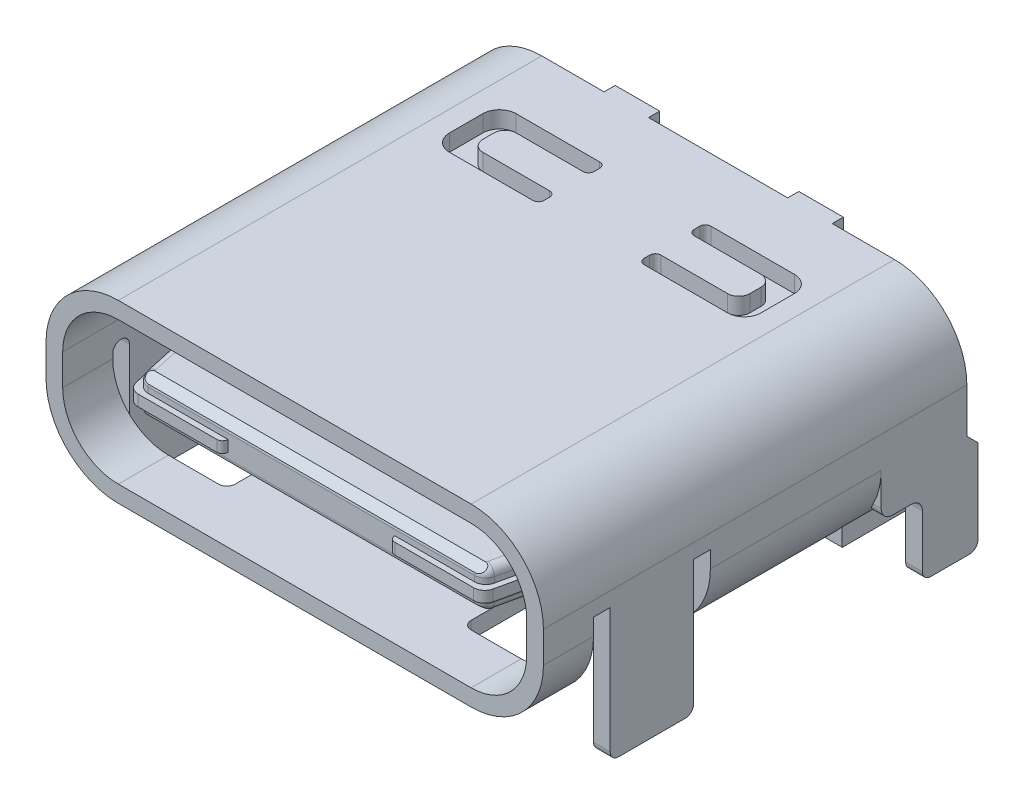
from build123d import *

# Parameters (mm, degrees)
BOSS_EXTRUDE1_DEPTH    = 7.61
SKETCH2_OUTSIDE_W      = 13.372
SKETCH2_OUTSIDE_H      = 7.592
CUT_EXTRUDE1_DEPTH     = 4.7
CUT_EXTRUDE2_DEPTH     = 0.3
BOSS_EXTRUDE2_DEPTH    = 0.2
BOSS_EXTRUDE3_DEPTH    = 0.3
CUT_EXTRUDE3_DEPTH     = 1.6
SKETCH7_W              = 8.34
SKETCH7_H              = 1.94
CUT_EXTRUDE4_DEPTH     = 0.15
BOSS_EXTRUDE4_DEPTH    = 1.94
BOSS_EXTRUDE5_DEPTH    = 0.2
BOSS_EXTRUDE5_2_DEPTH  = 0.2
BOSS_EXTRUDE5_3_DEPTH  = 0.2
BOSS_EXTRUDE5_4_DEPTH  = 0.2
BOSS_EXTRUDE5_5_DEPTH  = 0.2
BOSS_EXTRUDE5_6_DEPTH  = 0.2
BOSS_EXTRUDE5_7_DEPTH  = 0.2
BOSS_EXTRUDE5_8_DEPTH  = 0.2
BOSS_EXTRUDE5_9_DEPTH  = 0.2
BOSS_EXTRUDE5_10_DEPTH = 0.2
BOSS_EXTRUDE5_11_DEPTH = 0.2
BOSS_EXTRUDE5_12_DEPTH = 0.2
BOSS_EXTRUDE5_13_DEPTH = 0.2
BOSS_EXTRUDE5_14_DEPTH = 0.2
BOSS_EXTRUDE5_15_DEPTH = 0.2
BOSS_EXTRUDE5_16_DEPTH = 0.2
BOSS_EXTRUDE5_17_DEPTH = 0.2
BOSS_EXTRUDE5_18_DEPTH = 0.2
BOSS_EXTRUDE5_19_DEPTH = 0.2
BOSS_EXTRUDE5_20_DEPTH = 0.2
BOSS_EXTRUDE5_21_DEPTH = 0.2
BOSS_EXTRUDE5_22_DEPTH = 0.2
BOSS_EXTRUDE5_23_DEPTH = 0.2
BOSS_EXTRUDE5_24_DEPTH = 0.2
BOSS_EXTRUDE5_25_DEPTH = 0.2
BOSS_EXTRUDE5_26_DEPTH = 0.2
CUT_EXTRUDE5_START     = -6.55
CUT_EXTRUDE5_DEPTH     = 6.9
CUT_EXTRUDE6_DEPTH     = 6.2
BOSS_EXTRUDE6_DEPTH    = 1.62
BOSS_EXTRUDE7_DEPTH    = 0.35
BOSS_EXTRUDE8_DEPTH    = 0.1
BOSS_EXTRUDE8_2_DEPTH  = 0.1
FILLET2_R              = 0.15
CUT_EXTRUDE10_DEPTH    = 9.9400001


with BuildPart() as part:
    # Sketch1 → Boss-Extrude1 (new body)
    with BuildSketch(Plane.XY):
        with BuildLine():
            Line((-4.47, 0.28), (-4.47, -0.28))
            ThreePointArc((-4.47, -0.28), (-4.089238816, -1.199238816), (-3.17, -1.58))
            Line((-3.17, -1.58), (3.17, -1.58))
            ThreePointArc((3.17, -1.58), (4.089238816, -1.199238816), (4.47, -0.28))
            Line((4.47, -0.28), (4.47, 0.28))
            ThreePointArc((4.47, 0.28), (4.089238816, 1.199238816), (3.17, 1.58))
            Line((3.17, 1.58), (-3.17, 1.58))
            ThreePointArc((-3.17, 1.58), (-4.089238816, 1.199238816), (-4.47, 0.28))
        make_face()
    extrude(amount=BOSS_EXTRUDE1_DEPTH)

    # Sketch2 outside → Cut-Extrude1 (cut)
    with BuildSketch(Plane.XY.offset(7.61)):
        Rectangle(SKETCH2_OUTSIDE_W, SKETCH2_OUTSIDE_H)
        with BuildLine():
            Line((-4.47, 0.28), (-4.47, -0.28))
            ThreePointArc((-4.47, -0.28), (-4.089238816, -1.199238816), (-3.17, -1.58))
            Line((-3.17, -1.58), (3.17, -1.58))
            ThreePointArc((3.17, -1.58), (4.089238816, -1.199238816), (4.47, -0.28))
            Line((4.47, -0.28), (4.47, 0.28))
            ThreePointArc((4.47, 0.28), (4.089238816, 1.199238816), (3.17, 1.58))
            Line((3.17, 1.58), (-3.17, 1.58))
            ThreePointArc((-3.17, 1.58), (-4.089238816, 1.199238816), (-4.47, 0.28))
        make_face(mode=Mode.SUBTRACT)
        with BuildLine():
            Line((3.17, 1.28), (-3.17, 1.28))
            ThreePointArc((-3.17, 1.28), (-3.877106781, 0.987106781), (-4.17, 0.28))
            Line((-4.17, 0.28), (-4.17, -0.28))
            ThreePointArc((-4.17, -0.28), (-3.877106781, -0.987106781), (-3.17, -1.28))
            Line((-3.17, -1.28), (3.17, -1.28))
            ThreePointArc((3.17, -1.28), (3.877106781, -0.987106781), (4.17, -0.28))
            Line((4.17, -0.28), (4.17, 0.28))
            ThreePointArc((4.17, 0.28), (3.877106781, 0.987106781), (3.17, 1.28))
        make_face()
    extrude(amount=-CUT_EXTRUDE1_DEPTH, mode=Mode.SUBTRACT)

    # Sketch3 → Cut-Extrude2 (cut)
    with BuildSketch(Plane(origin=(0, 1.58, 0), x_dir=(1, 0, 0), z_dir=(0, 1, 0))):
        with BuildLine():
            Line((-0.9, -1.33), (-0.9, -1.23))
            ThreePointArc((-0.9, -1.23), (-0.929289322, -1.159289322), (-1, -1.13))
            Line((-1, -1.13), (-2.5, -1.13))
            ThreePointArc((-2.5, -1.13), (-2.712132034, -1.217867966), (-2.8, -1.43))
            Line((-2.8, -1.43), (-2.8, -2.03))
            ThreePointArc((-2.8, -2.03), (-2.712132034, -2.242132034), (-2.5, -2.33))
            Line((-2.5, -2.33), (-1, -2.33))
            ThreePointArc((-1, -2.33), (-0.929289322, -2.300710678), (-0.9, -2.23))
            Line((-0.9, -2.23), (-0.9, -2.13))
            ThreePointArc((-0.9, -2.13), (-0.929289322, -2.059289322), (-1, -2.03))
            Line((-1, -2.03), (-2.2, -2.03))
            ThreePointArc((-2.2, -2.03), (-2.341421356, -1.971421356), (-2.4, -1.83))
            Line((-2.4, -1.83), (-2.4, -1.63))
            ThreePointArc((-2.4, -1.63), (-2.341421356, -1.488578644), (-2.2, -1.43))
            Line((-2.2, -1.43), (-1, -1.43))
            ThreePointArc((-1, -1.43), (-0.929289322, -1.400710678), (-0.9, -1.33))
        make_face()
        with BuildLine():
            Line((2.5, -1.13), (1, -1.13))
            ThreePointArc((1, -1.13), (0.929289322, -1.159289322), (0.9, -1.23))
            Line((0.9, -1.23), (0.9, -1.33))
            ThreePointArc((0.9, -1.33), (0.929289322, -1.400710678), (1, -1.43))
            Line((1, -1.43), (2.2, -1.43))
            ThreePointArc((2.2, -1.43), (2.341421356, -1.488578644), (2.4, -1.63))
            Line((2.4, -1.63), (2.4, -1.83))
            ThreePointArc((2.4, -1.83), (2.341421356, -1.971421356), (2.2, -2.03))
            Line((2.2, -2.03), (1, -2.03))
            ThreePointArc((1, -2.03), (0.929289322, -2.059289322), (0.9, -2.13))
            Line((0.9, -2.13), (0.9, -2.23))
            ThreePointArc((0.9, -2.23), (0.929289322, -2.300710678), (1, -2.33))
            Line((1, -2.33), (2.5, -2.33))
            ThreePointArc((2.5, -2.33), (2.712132034, -2.242132034), (2.8, -2.03))
            Line((2.8, -2.03), (2.8, -1.43))
            ThreePointArc((2.8, -1.43), (2.712132034, -1.217867966), (2.5, -1.13))
        make_face()
    extrude(amount=-CUT_EXTRUDE2_DEPTH, mode=Mode.SUBTRACT)

    # Sketch4 → Boss-Extrude2 (add)
    with BuildSketch(Plane(origin=(0, 0, 0), x_dir=(-1, 0, 0), z_dir=(0, 0, -1))):
        with BuildLine():
            Line((-3.97, 0.48), (-3.97, -0.42))
            ThreePointArc((-3.97, -0.42), (-3.882132034, -0.632132034), (-3.67, -0.72))
            Line((-3.67, -0.72), (3.67, -0.72))
            ThreePointArc((3.67, -0.72), (3.882132034, -0.632132034), (3.97, -0.42))
            Line((3.97, -0.42), (3.97, 0.48))
            ThreePointArc((3.97, 0.48), (3.823553391, 0.833553391), (3.47, 0.98))
            Line((3.47, 0.98), (2.05, 0.98))
            Line((2.05, 0.98), (2.05, 1.58))
            Line((2.05, 1.58), (1.25, 1.58))
            Line((1.25, 1.58), (1.25, 0.98))
            Line((1.25, 0.98), (-1.25, 0.98))
            Line((-1.25, 0.98), (-1.25, 1.58))
            Line((-1.25, 1.58), (-2.05, 1.58))
            Line((-2.05, 1.58), (-2.05, 0.98))
            Line((-2.05, 0.98), (-3.47, 0.98))
            ThreePointArc((-3.47, 0.98), (-3.823553391, 0.833553391), (-3.97, 0.48))
        make_face()
    extrude(amount=BOSS_EXTRUDE2_DEPTH)

    # Sketch5 → Boss-Extrude3 (add)
    with BuildSketch(Plane(origin=(4.47, 0, 0), x_dir=(0, 0, -1), z_dir=(1, 0, 0))):
        with BuildLine():
            Line((-4.91, -0.28), (-6.41, -0.28))
            Line((-6.41, -0.28), (-6.41, -2.23))
            ThreePointArc((-6.41, -2.23), (-6.366066017, -2.336066017), (-6.26, -2.38))
            Line((-6.26, -2.38), (-5.06, -2.38))
            ThreePointArc((-5.06, -2.38), (-4.953933983, -2.336066017), (-4.91, -2.23))
            Line((-4.91, -2.23), (-4.91, -0.28))
        make_face()
        with BuildLine():
            ThreePointArc((-6.71, -0.2), (-6.56, -0.05), (-6.41, -0.2))
            Line((-6.41, -0.2), (-6.41, -0.28))
            Line((-6.41, -0.28), (-4.91, -0.28))
            Line((-4.91, -0.28), (-4.91, -0.2))
            ThreePointArc((-4.91, -0.2), (-4.76, -0.05), (-4.61, -0.2))
            Line((-4.61, -0.2), (-4.61, -0.28))
            Line((-4.61, -0.28), (-1.54, -0.28))
            Line((-1.54, -0.28), (0, -0.28))
            Line((0, -0.28), (0, 0.209679923))
            Line((0, 0.209679923), (-7.61, 0.209679923))
            Line((-7.61, 0.209679923), (-7.61, -0.28))
            Line((-7.61, -0.28), (-6.71, -0.28))
            Line((-6.71, -0.28), (-6.71, -0.2))
        make_face()
        with BuildLine():
            Line((0, -0.28), (-1.54, -0.28))
            Line((-1.54, -0.28), (-1.54, -0.88))
            ThreePointArc((-1.54, -0.88), (-1.481421356, -1.021421356), (-1.34, -1.08))
            Line((-1.34, -1.08), (-1, -1.08))
            ThreePointArc((-1, -1.08), (-0.858578644, -1.138578644), (-0.8, -1.28))
            Line((-0.8, -1.28), (-0.8, -2.23))
            ThreePointArc((-0.8, -2.23), (-0.756066017, -2.336066017), (-0.65, -2.38))
            Line((-0.65, -2.38), (0.05, -2.38))
            ThreePointArc((0.05, -2.38), (0.156066017, -2.336066017), (0.2, -2.23))
            Line((0.2, -2.23), (0.2, -0.72))
            Line((0.2, -0.72), (0, -0.52))
            Line((0, -0.52), (0, -0.28))
        make_face()
    boss_extrude3 = extrude(amount=-BOSS_EXTRUDE3_DEPTH)

    # Sketch6 → Cut-Extrude3 (cut)
    with BuildSketch(Plane.XZ.offset(1.58)):
        with BuildLine():
            Line((4.47, 4.61), (3.17, 4.61))
            Line((3.17, 4.61), (2.27, 4.61))
            ThreePointArc((2.27, 4.61), (2.163933983, 4.653933983), (2.12, 4.76))
            Line((2.12, 4.76), (2.12, 6.56))
            ThreePointArc((2.12, 6.56), (2.163933983, 6.666066017), (2.27, 6.71))
            Line((2.27, 6.71), (3.17, 6.71))
            Line((3.17, 6.71), (4.47, 6.71))
            Line((4.47, 6.71), (4.47, 6.41))
            Line((4.47, 6.41), (4.17, 6.41))
            Line((4.17, 6.41), (4.17, 4.91))
            Line((4.17, 4.91), (4.47, 4.91))
            Line((4.47, 4.91), (4.47, 4.61))
        make_face()
        with BuildLine():
            Line((-3.17, 4.61), (-4.47, 4.61))
            Line((-4.47, 4.61), (-4.47, 6.71))
            Line((-4.47, 6.71), (-3.17, 6.71))
            Line((-3.17, 6.71), (-2.27, 6.71))
            ThreePointArc((-2.27, 6.71), (-2.163933983, 6.666066017), (-2.12, 6.56))
            Line((-2.12, 6.56), (-2.12, 4.76))
            ThreePointArc((-2.12, 4.76), (-2.163933983, 4.653933983), (-2.27, 4.61))
            Line((-2.27, 4.61), (-3.17, 4.61))
        make_face()
    extrude(amount=-CUT_EXTRUDE3_DEPTH, mode=Mode.SUBTRACT)

    # Sketch7 → Cut-Extrude4 (cut)
    with BuildSketch(Plane.XZ.offset(1.58)):
        with Locations((0, 0.97)):
            Rectangle(SKETCH7_W, SKETCH7_H)
    extrude(amount=-CUT_EXTRUDE4_DEPTH, mode=Mode.SUBTRACT)

    # Sketch8 → Boss-Extrude4 (add)
    with BuildSketch(Plane(origin=(0, 0, 0), x_dir=(-1, 0, 0), z_dir=(0, 0, -1))):
        with BuildLine():
            Line((-3.776217783, -1.43), (-4.17, -1.43))
            Line((-4.17, -1.43), (-4.17, -1.110662386))
            ThreePointArc((-4.17, -1.110662386), (-3.988827222, -1.289713811), (-3.776217783, -1.43))
        make_face()
        with BuildLine():
            Line((4.17, -1.43), (4.17, -1.110662386))
            ThreePointArc((4.17, -1.110662386), (3.988827222, -1.289713811), (3.776217783, -1.43))
            Line((3.776217783, -1.43), (4.17, -1.43))
        make_face()
    extrude(amount=-BOSS_EXTRUDE4_DEPTH)

    # Mirror1: Boss-Extrude3 across plane
    add(boss_extrude3.mirror(Plane.ZY))


with BuildPart() as body_2:
    # Sketch9 → Boss-Extrude5 (new body)
    with BuildSketch(Plane.XZ.offset(1.43)):
        Polygon((-0.6, 0.05), (-0.6, -0.29), (-0.4, -0.29), (-0.4, 0.05), (-0.4, 0.2), (-0.6, 0.2), align=None)
    extrude(amount=BOSS_EXTRUDE5_DEPTH)


with BuildPart() as body_3:
    # Sketch9 → Boss-Extrude5 2 (new body)
    with BuildSketch(Plane.XZ.offset(1.43)):
        Polygon((-0.9, 0.05), (-0.9, 0.2), (-1.1, 0.2), (-1.1, 0.05), (-1.1, -0.29), (-0.9, -0.29), align=None)
    extrude(amount=BOSS_EXTRUDE5_2_DEPTH)


with BuildPart() as body_4:
    # Sketch9 → Boss-Extrude5 3 (new body)
    with BuildSketch(Plane.XZ.offset(1.43)):
        Polygon((-1.6, 0.05), (-1.6, -0.29), (-1.4, -0.29), (-1.4, 0.05), (-1.4, 0.2), (-1.6, 0.2), align=None)
    extrude(amount=BOSS_EXTRUDE5_3_DEPTH)


with BuildPart() as body_5:
    # Sketch9 → Boss-Extrude5 4 (new body)
    with BuildSketch(Plane.XZ.offset(1.43)):
        Polygon((-1.9, 0.05), (-1.9, 0.2), (-2.1, 0.2), (-2.1, 0.05), (-2.1, -0.29), (-1.9, -0.29), align=None)
    extrude(amount=BOSS_EXTRUDE5_4_DEPTH)


with BuildPart() as body_6:
    # Sketch9 → Boss-Extrude5 5 (new body)
    with BuildSketch(Plane.XZ.offset(1.43)):
        Polygon((-2.6, 0.05), (-2.6, -0.29), (-2.4, -0.29), (-2.4, 0.05), (-2.4, 0.2), (-2.6, 0.2), align=None)
    extrude(amount=BOSS_EXTRUDE5_5_DEPTH)


with BuildPart() as body_7:
    # Sketch9 → Boss-Extrude5 6 (new body)
    with BuildSketch(Plane.XZ.offset(1.43)):
        Polygon((-2.9, 0.05), (-2.9, 0.2), (-3.1, 0.2), (-3.1, 0.05), (-3.1, -0.29), (-2.9, -0.29), align=None)
    extrude(amount=BOSS_EXTRUDE5_6_DEPTH)


with BuildPart() as body_8:
    # Sketch9 → Boss-Extrude5 7 (new body)
    with BuildSketch(Plane.XZ.offset(1.43)):
        Polygon((0.6, 0.05), (0.6, 0.2), (0.4, 0.2), (0.4, 0.05), (0.4, -0.29), (0.6, -0.29), align=None)
    extrude(amount=BOSS_EXTRUDE5_7_DEPTH)


with BuildPart() as body_9:
    # Sketch9 → Boss-Extrude5 8 (new body)
    with BuildSketch(Plane.XZ.offset(1.43)):
        Polygon((0.9, 0.05), (0.9, -0.29), (1.1, -0.29), (1.1, 0.05), (1.1, 0.2), (0.9, 0.2), align=None)
    extrude(amount=BOSS_EXTRUDE5_8_DEPTH)


with BuildPart() as body_10:
    # Sketch9 → Boss-Extrude5 9 (new body)
    with BuildSketch(Plane.XZ.offset(1.43)):
        Polygon((1.6, 0.05), (1.6, 0.2), (1.4, 0.2), (1.4, 0.05), (1.4, -0.29), (1.6, -0.29), align=None)
    extrude(amount=BOSS_EXTRUDE5_9_DEPTH)


with BuildPart() as body_11:
    # Sketch9 → Boss-Extrude5 10 (new body)
    with BuildSketch(Plane.XZ.offset(1.43)):
        Polygon((1.9, 0.05), (1.9, -0.29), (2.1, -0.29), (2.1, 0.05), (2.1, 0.2), (1.9, 0.2), align=None)
    extrude(amount=BOSS_EXTRUDE5_10_DEPTH)


with BuildPart() as body_12:
    # Sketch9 → Boss-Extrude5 11 (new body)
    with BuildSketch(Plane.XZ.offset(1.43)):
        Polygon((2.6, 0.05), (2.6, 0.2), (2.4, 0.2), (2.4, 0.05), (2.4, -0.29), (2.6, -0.29), align=None)
    extrude(amount=BOSS_EXTRUDE5_11_DEPTH)


with BuildPart() as body_13:
    # Sketch9 → Boss-Extrude5 12 (new body)
    with BuildSketch(Plane.XZ.offset(1.43)):
        Polygon((2.9, 0.05), (2.9, -0.29), (3.1, -0.29), (3.1, 0.05), (3.1, 0.2), (2.9, 0.2), align=None)
    extrude(amount=BOSS_EXTRUDE5_12_DEPTH)


with BuildPart() as body_14:
    # Sketch9 → Boss-Extrude5 13 (new body)
    with BuildSketch(Plane.XZ.offset(1.43)):
        Polygon((2.65, 1.31), (2.65, 1.01), (2.85, 1.01), (2.85, 1.31), (2.85, 1.46), (2.65, 1.46), align=None)
    extrude(amount=BOSS_EXTRUDE5_13_DEPTH)


with BuildPart() as body_15:
    # Sketch9 → Boss-Extrude5 14 (new body)
    with BuildSketch(Plane.XZ.offset(1.43)):
        Polygon((3.45, 1.31), (3.45, 1.46), (3.15, 1.46), (3.15, 1.31), (3.15, 1.01), (3.45, 1.01), align=None)
    extrude(amount=BOSS_EXTRUDE5_14_DEPTH)


with BuildPart() as body_16:
    # Sketch9 → Boss-Extrude5 15 (new body)
    with BuildSketch(Plane.XZ.offset(1.43)):
        Polygon((2.15, 1.31), (2.15, 1.01), (2.35, 1.01), (2.35, 1.31), (2.35, 1.46), (2.15, 1.46), align=None)
    extrude(amount=BOSS_EXTRUDE5_15_DEPTH)


with BuildPart() as body_17:
    # Sketch9 → Boss-Extrude5 16 (new body)
    with BuildSketch(Plane.XZ.offset(1.43)):
        Polygon((1.85, 1.31), (1.85, 1.46), (1.65, 1.46), (1.65, 1.31), (1.65, 1.01), (1.85, 1.01), align=None)
    extrude(amount=BOSS_EXTRUDE5_16_DEPTH)


with BuildPart() as body_18:
    # Sketch9 → Boss-Extrude5 17 (new body)
    with BuildSketch(Plane.XZ.offset(1.43)):
        Polygon((1.15, 1.31), (1.15, 1.01), (1.35, 1.01), (1.35, 1.31), (1.35, 1.46), (1.15, 1.46), align=None)
    extrude(amount=BOSS_EXTRUDE5_17_DEPTH)


with BuildPart() as body_19:
    # Sketch9 → Boss-Extrude5 18 (new body)
    with BuildSketch(Plane.XZ.offset(1.43)):
        Polygon((0.85, 1.31), (0.85, 1.46), (0.65, 1.46), (0.65, 1.31), (0.65, 1.01), (0.85, 1.01), align=None)
    extrude(amount=BOSS_EXTRUDE5_18_DEPTH)


with BuildPart() as body_20:
    # Sketch9 → Boss-Extrude5 19 (new body)
    with BuildSketch(Plane.XZ.offset(1.43)):
        Polygon((0.15, 1.31), (0.15, 1.01), (0.35, 1.01), (0.35, 1.31), (0.35, 1.46), (0.15, 1.46), align=None)
    extrude(amount=BOSS_EXTRUDE5_19_DEPTH)


with BuildPart() as body_21:
    # Sketch9 → Boss-Extrude5 20 (new body)
    with BuildSketch(Plane.XZ.offset(1.43)):
        Polygon((-0.15, 1.31), (-0.15, 1.46), (-0.35, 1.46), (-0.35, 1.31), (-0.35, 1.01), (-0.15, 1.01), align=None)
    extrude(amount=BOSS_EXTRUDE5_20_DEPTH)


with BuildPart() as body_22:
    # Sketch9 → Boss-Extrude5 21 (new body)
    with BuildSketch(Plane.XZ.offset(1.43)):
        Polygon((-0.85, 1.31), (-0.85, 1.01), (-0.65, 1.01), (-0.65, 1.31), (-0.65, 1.46), (-0.85, 1.46), align=None)
    extrude(amount=BOSS_EXTRUDE5_21_DEPTH)


with BuildPart() as body_23:
    # Sketch9 → Boss-Extrude5 22 (new body)
    with BuildSketch(Plane.XZ.offset(1.43)):
        Polygon((-1.15, 1.31), (-1.15, 1.46), (-1.35, 1.46), (-1.35, 1.31), (-1.35, 1.01), (-1.15, 1.01), align=None)
    extrude(amount=BOSS_EXTRUDE5_22_DEPTH)


with BuildPart() as body_24:
    # Sketch9 → Boss-Extrude5 23 (new body)
    with BuildSketch(Plane.XZ.offset(1.43)):
        Polygon((-1.85, 1.31), (-1.85, 1.01), (-1.65, 1.01), (-1.65, 1.31), (-1.65, 1.46), (-1.85, 1.46), align=None)
    extrude(amount=BOSS_EXTRUDE5_23_DEPTH)


with BuildPart() as body_25:
    # Sketch9 → Boss-Extrude5 24 (new body)
    with BuildSketch(Plane.XZ.offset(1.43)):
        Polygon((-2.15, 1.31), (-2.15, 1.46), (-2.35, 1.46), (-2.35, 1.31), (-2.35, 1.01), (-2.15, 1.01), align=None)
    extrude(amount=BOSS_EXTRUDE5_24_DEPTH)


with BuildPart() as body_26:
    # Sketch9 → Boss-Extrude5 25 (new body)
    with BuildSketch(Plane.XZ.offset(1.43)):
        Polygon((-2.85, 1.31), (-2.85, 1.01), (-2.65, 1.01), (-2.65, 1.31), (-2.65, 1.46), (-2.85, 1.46), align=None)
    extrude(amount=BOSS_EXTRUDE5_25_DEPTH)


with BuildPart() as body_27:
    # Sketch9 → Boss-Extrude5 26 (new body)
    with BuildSketch(Plane.XZ.offset(1.43)):
        Polygon((-3.15, 1.31), (-3.15, 1.46), (-3.45, 1.46), (-3.45, 1.31), (-3.45, 1.01), (-3.15, 1.01), align=None)
    extrude(amount=BOSS_EXTRUDE5_26_DEPTH)


with BuildPart() as cut_extrude5_tool:
    # Sketch10 → Cut-Extrude5 (new body)
    with BuildSketch(Plane.ZY.offset(3.1).offset(CUT_EXTRUDE5_START)):
        with BuildLine():
            Line((1.01, -1.63), (1.31711545, -1.63))
            ThreePointArc((1.31711545, -1.63), (1.418150084, -1.588150084), (1.46, -1.48711545))
            Line((1.46, -1.48711545), (1.46, -1.43))
            Line((1.46, -1.43), (1.57898756, -1.531986034))
            Line((1.57898756, -1.531986034), (1.518730657, -1.78951256))
            Line((1.518730657, -1.78951256), (1.01, -1.63))
        make_face()
        with BuildLine():
            Line((-0.29, -1.63), (0.099975763, -1.63))
            ThreePointArc((0.099975763, -1.63), (0.170702109, -1.600719248), (0.2, -1.53))
            Line((0.2, -1.53), (0.2, -1.43))
            Line((0.2, -1.43), (0.448197351, -1.776454988))
            Line((0.448197351, -1.776454988), (0.039944898, -1.806792797))
            Line((0.039944898, -1.806792797), (-0.29, -1.63))
        make_face()
    extrude(amount=CUT_EXTRUDE5_DEPTH)


with BuildPart() as body_14_1:
    add(body_14.part)

    # Cut-Extrude5: cut by cut_extrude5_tool
    add(cut_extrude5_tool.part, mode=Mode.SUBTRACT)


with BuildPart() as body_15_1:
    add(body_15.part)

    # Cut-Extrude5: cut by cut_extrude5_tool
    add(cut_extrude5_tool.part, mode=Mode.SUBTRACT)


with BuildPart() as body_16_1:
    add(body_16.part)

    # Cut-Extrude5: cut by cut_extrude5_tool
    add(cut_extrude5_tool.part, mode=Mode.SUBTRACT)


with BuildPart() as body_17_1:
    add(body_17.part)

    # Cut-Extrude5: cut by cut_extrude5_tool
    add(cut_extrude5_tool.part, mode=Mode.SUBTRACT)


with BuildPart() as body_18_1:
    add(body_18.part)

    # Cut-Extrude5: cut by cut_extrude5_tool
    add(cut_extrude5_tool.part, mode=Mode.SUBTRACT)


with BuildPart() as body_19_1:
    add(body_19.part)

    # Cut-Extrude5: cut by cut_extrude5_tool
    add(cut_extrude5_tool.part, mode=Mode.SUBTRACT)


with BuildPart() as body_20_1:
    add(body_20.part)

    # Cut-Extrude5: cut by cut_extrude5_tool
    add(cut_extrude5_tool.part, mode=Mode.SUBTRACT)


with BuildPart() as body_21_1:
    add(body_21.part)

    # Cut-Extrude5: cut by cut_extrude5_tool
    add(cut_extrude5_tool.part, mode=Mode.SUBTRACT)


with BuildPart() as body_22_1:
    add(body_22.part)

    # Cut-Extrude5: cut by cut_extrude5_tool
    add(cut_extrude5_tool.part, mode=Mode.SUBTRACT)


with BuildPart() as body_23_1:
    add(body_23.part)

    # Cut-Extrude5: cut by cut_extrude5_tool
    add(cut_extrude5_tool.part, mode=Mode.SUBTRACT)


with BuildPart() as body_24_1:
    add(body_24.part)

    # Cut-Extrude5: cut by cut_extrude5_tool
    add(cut_extrude5_tool.part, mode=Mode.SUBTRACT)


with BuildPart() as body_25_1:
    add(body_25.part)

    # Cut-Extrude5: cut by cut_extrude5_tool
    add(cut_extrude5_tool.part, mode=Mode.SUBTRACT)


with BuildPart() as body_26_1:
    add(body_26.part)

    # Cut-Extrude5: cut by cut_extrude5_tool
    add(cut_extrude5_tool.part, mode=Mode.SUBTRACT)


with BuildPart() as body_27_1:
    add(body_27.part)

    # Cut-Extrude5: cut by cut_extrude5_tool
    add(cut_extrude5_tool.part, mode=Mode.SUBTRACT)


with BuildPart() as cut_extrude6_tool:
    # Sketch11 → Cut-Extrude6 (new body)
    with BuildSketch(Plane.ZY.offset(3.1)):
        with BuildLine():
            Line((-0.29, -1.63), (0.099975763, -1.63))
            ThreePointArc((0.099975763, -1.63), (0.170702109, -1.600719248), (0.2, -1.53))
            Line((0.2, -1.53), (0.2, -1.43))
            Line((0.2, -1.43), (0.448197351, -1.776454988))
            Line((0.448197351, -1.776454988), (0.039944898, -1.806792797))
            Line((0.039944898, -1.806792797), (-0.29, -1.63))
        make_face()
    extrude(amount=-CUT_EXTRUDE6_DEPTH)


with BuildPart() as body_2_1:
    add(body_2.part)

    # Cut-Extrude6: cut by cut_extrude6_tool
    add(cut_extrude6_tool.part, mode=Mode.SUBTRACT)


with BuildPart() as body_3_1:
    add(body_3.part)

    # Cut-Extrude6: cut by cut_extrude6_tool
    add(cut_extrude6_tool.part, mode=Mode.SUBTRACT)


with BuildPart() as body_4_1:
    add(body_4.part)

    # Cut-Extrude6: cut by cut_extrude6_tool
    add(cut_extrude6_tool.part, mode=Mode.SUBTRACT)


with BuildPart() as body_5_1:
    add(body_5.part)

    # Cut-Extrude6: cut by cut_extrude6_tool
    add(cut_extrude6_tool.part, mode=Mode.SUBTRACT)


with BuildPart() as body_6_1:
    add(body_6.part)

    # Cut-Extrude6: cut by cut_extrude6_tool
    add(cut_extrude6_tool.part, mode=Mode.SUBTRACT)


with BuildPart() as body_7_1:
    add(body_7.part)

    # Cut-Extrude6: cut by cut_extrude6_tool
    add(cut_extrude6_tool.part, mode=Mode.SUBTRACT)


with BuildPart() as body_8_1:
    add(body_8.part)

    # Cut-Extrude6: cut by cut_extrude6_tool
    add(cut_extrude6_tool.part, mode=Mode.SUBTRACT)


with BuildPart() as body_9_1:
    add(body_9.part)

    # Cut-Extrude6: cut by cut_extrude6_tool
    add(cut_extrude6_tool.part, mode=Mode.SUBTRACT)


with BuildPart() as body_10_1:
    add(body_10.part)

    # Cut-Extrude6: cut by cut_extrude6_tool
    add(cut_extrude6_tool.part, mode=Mode.SUBTRACT)


with BuildPart() as body_11_1:
    add(body_11.part)

    # Cut-Extrude6: cut by cut_extrude6_tool
    add(cut_extrude6_tool.part, mode=Mode.SUBTRACT)


with BuildPart() as body_12_1:
    add(body_12.part)

    # Cut-Extrude6: cut by cut_extrude6_tool
    add(cut_extrude6_tool.part, mode=Mode.SUBTRACT)


with BuildPart() as body_13_1:
    add(body_13.part)

    # Cut-Extrude6: cut by cut_extrude6_tool
    add(cut_extrude6_tool.part, mode=Mode.SUBTRACT)


with BuildPart() as body_28:
    # Sketch12 → Boss-Extrude6 (new body)
    with BuildSketch(Plane.XY.offset(2.91)):
        with BuildLine():
            Line((-3.165, 0.2), (-3.165, -0.2))
            ThreePointArc((-3.165, -0.2), (-3.077132034, -0.412132034), (-2.865, -0.5))
            Line((-2.865, -0.5), (2.865, -0.5))
            ThreePointArc((2.865, -0.5), (3.077132034, -0.412132034), (3.165, -0.2))
            Line((3.165, -0.2), (3.165, 0.2))
            ThreePointArc((3.165, 0.2), (3.077132034, 0.412132034), (2.865, 0.5))
            Line((2.865, 0.5), (-2.865, 0.5))
            ThreePointArc((-2.865, 0.5), (-3.077132034, 0.412132034), (-3.165, 0.2))
        make_face()
    extrude(amount=BOSS_EXTRUDE6_DEPTH)

    # Sketch13 → Boss-Extrude7 (add, symmetric)
    with BuildSketch(Plane(origin=(0, 0, 0), x_dir=(1, 0, 0), z_dir=(0, 1, 0))):
        with BuildLine():
            Line((3.045, -6.06), (3.045, -4.53))
            Line((3.045, -4.53), (-3.045, -4.53))
            Line((-3.045, -4.53), (-3.045, -6.06))
            ThreePointArc((-3.045, -6.06), (-3.055557281, -6.104721359), (-3.085, -6.14))
            Line((-3.085, -6.14), (-3.205, -6.23))
            ThreePointArc((-3.205, -6.23), (-3.234442719, -6.26527864), (-3.245, -6.31))
            Line((-3.245, -6.31), (-3.245, -6.61))
            ThreePointArc((-3.245, -6.61), (-3.243816482, -6.631725709), (-3.240279936, -6.65319429))
            Line((-3.240279936, -6.65319429), (-3.129684113, -7.15319429))
            ThreePointArc((-3.129684113, -7.15319429), (-3.106674261, -7.211602255), (-3.066691743, -7.26))
            ThreePointArc((-3.066691743, -7.26), (-3.005114855, -7.297082869), (-2.934404177, -7.31))
            Line((-2.934404177, -7.31), (2.934404177, -7.31))
            ThreePointArc((2.934404177, -7.31), (3.005114855, -7.297082869), (3.066691743, -7.26))
            ThreePointArc((3.066691743, -7.26), (3.106674261, -7.211602255), (3.129684113, -7.15319429))
            Line((3.129684113, -7.15319429), (3.240279936, -6.65319429))
            ThreePointArc((3.240279936, -6.65319429), (3.243816482, -6.631725709), (3.245, -6.61))
            Line((3.245, -6.61), (3.245, -6.31))
            ThreePointArc((3.245, -6.31), (3.242324899, -6.287024708), (3.234442719, -6.265278641))
            ThreePointArc((3.234442719, -6.265278641), (3.221775173, -6.245925256), (3.205, -6.23))
            Line((3.205, -6.23), (3.085, -6.14))
            ThreePointArc((3.085, -6.14), (3.055557281, -6.10472136), (3.045, -6.06))
        make_face()
    extrude(amount=BOSS_EXTRUDE7_DEPTH, both=True)

    # Fillet2
    fillet2_edges = [body_28.edges().sort_by_distance(p)[0] for p in [
        (3.055557281, -0.35, 6.10472136),
        (3.045, -0.35, 5.295),
        (-3.045, -0.35, 5.295),
        (-3.055557281, -0.35, 6.104721359),
        (-3.145, -0.35, 6.185),
        (-3.234442719, -0.35, 6.26527864),
        (-3.245, -0.35, 6.46),
        (-3.243816482, -0.35, 6.631725709),
        (-3.184982024, -0.35, 6.90319429),
        (-3.059626264, -0.35, 7.265946879),
        (0, -0.35, 7.31),
        (3.059626264, -0.35, 7.265946879),
        (3.184982024, -0.35, 6.90319429),
        (3.243816482, -0.35, 6.631725709),
        (3.245, -0.35, 6.46),
        (3.234442719, -0.35, 6.265278641),
        (3.145, -0.35, 6.185),
        (3.055557281, 0.35, 6.10472136),
        (3.045, 0.35, 5.295),
        (-3.045, 0.35, 5.295),
        (-3.055557281, 0.35, 6.104721359),
        (-3.145, 0.35, 6.185),
        (-3.234442719, 0.35, 6.26527864),
        (-3.245, 0.35, 6.46),
        (-3.243816482, 0.35, 6.631725709),
        (-3.184982024, 0.35, 6.90319429),
        (-3.059626264, 0.35, 7.265946879),
        (0, 0.35, 7.31),
        (3.059626264, 0.35, 7.265946879),
        (3.184982024, 0.35, 6.90319429),
        (3.243816482, 0.35, 6.631725709),
        (3.245, 0.35, 6.46),
        (3.234442719, 0.35, 6.265278641),
        (3.145, 0.35, 6.185),
    ]]
    fillet(fillet2_edges, radius=FILLET2_R)

    # Sketch16 → Cut-Extrude10 (cut, through all)
    with BuildSketch(Plane(origin=(4.47, 0, 0), x_dir=(0, 0, -1), z_dir=(1, 0, 0))):
        Polygon((-7.363317357, -0.373330152), (-7.336052533, -0.218202706), (-7.117933943, -0.373330152), align=None)
        Polygon((-7.363317357, 0.373330152), (-7.336052533, 0.218202706), (-7.117933943, 0.373330152), align=None)
    extrude(amount=-CUT_EXTRUDE10_DEPTH, mode=Mode.SUBTRACT)


with BuildPart() as body_29:
    # Sketch14 → Boss-Extrude8 (new body, symmetric)
    with BuildSketch(Plane(origin=(0, 0, 0), x_dir=(1, 0, 0), z_dir=(0, 1, 0))):
        with BuildLine():
            Line((-3.205, -6.23), (-3.085, -6.14))
            ThreePointArc((-3.085, -6.14), (-3.055557281, -6.104721359), (-3.045, -6.06))
            Line((-3.045, -6.06), (-3.045, -4.53))
            Line((-3.045, -4.53), (-3.091053964, -4.53))
            Line((-3.091053964, -4.53), (-3.091053964, -5.969540473))
            ThreePointArc((-3.091053964, -5.969540473), (-3.101611245, -6.014261832), (-3.131053964, -6.049540473))
            Line((-3.131053964, -6.049540473), (-3.305, -6.18))
            ThreePointArc((-3.305, -6.18), (-3.334442719, -6.21527864), (-3.345, -6.26))
            Line((-3.345, -6.26), (-3.345, -6.620927519))
            ThreePointArc((-3.345, -6.620927519), (-3.343816482, -6.642653228), (-3.340279936, -6.664121809))
            Line((-3.340279936, -6.664121809), (-3.209982024, -7.25319429))
            ThreePointArc((-3.209982024, -7.25319429), (-3.139924175, -7.365946879), (-3.014702089, -7.41))
            Line((-3.014702089, -7.41), (-1.6, -7.41))
            ThreePointArc((-1.6, -7.41), (-1.529289322, -7.380710678), (-1.5, -7.31))
            Line((-1.5, -7.31), (-2.934404177, -7.31))
            ThreePointArc((-2.934404177, -7.31), (-3.059626264, -7.265946879), (-3.129684113, -7.15319429))
            Line((-3.129684113, -7.15319429), (-3.240279936, -6.65319429))
            ThreePointArc((-3.240279936, -6.65319429), (-3.243816482, -6.631725709), (-3.245, -6.61))
            Line((-3.245, -6.61), (-3.245, -6.31))
            ThreePointArc((-3.245, -6.31), (-3.234442719, -6.26527864), (-3.205, -6.23))
        make_face()
    extrude(amount=BOSS_EXTRUDE8_DEPTH, both=True)


with BuildPart() as body_30:
    # Sketch14 → Boss-Extrude8 2 (new body, symmetric)
    with BuildSketch(Plane(origin=(0, 0, 0), x_dir=(1, 0, 0), z_dir=(0, 1, 0))):
        with BuildLine():
            Line((3.305, -6.18), (3.131053964, -6.049540473))
            ThreePointArc((3.131053964, -6.049540473), (3.101611245, -6.014261832), (3.091053964, -5.969540473))
            Line((3.091053964, -5.969540473), (3.091053964, -4.53))
            Line((3.091053964, -4.53), (3.045, -4.53))
            Line((3.045, -4.53), (3.045, -6.06))
            ThreePointArc((3.045, -6.06), (3.055557281, -6.10472136), (3.085, -6.14))
            Line((3.085, -6.14), (3.205, -6.23))
            ThreePointArc((3.205, -6.23), (3.234442719, -6.265278641), (3.245, -6.31))
            Line((3.245, -6.31), (3.245, -6.61))
            ThreePointArc((3.245, -6.61), (3.243816482, -6.631725709), (3.240279936, -6.65319429))
            Line((3.240279936, -6.65319429), (3.129684113, -7.15319429))
            ThreePointArc((3.129684113, -7.15319429), (3.059626264, -7.265946879), (2.934404177, -7.31))
            Line((2.934404177, -7.31), (1.5, -7.31))
            ThreePointArc((1.5, -7.31), (1.529289322, -7.380710678), (1.6, -7.41))
            Line((1.6, -7.41), (3.014702089, -7.41))
            ThreePointArc((3.014702089, -7.41), (3.139924175, -7.365946879), (3.209982024, -7.25319429))
            Line((3.209982024, -7.25319429), (3.340279936, -6.664121809))
            ThreePointArc((3.340279936, -6.664121809), (3.343816482, -6.642653228), (3.345, -6.620927519))
            Line((3.345, -6.620927519), (3.345, -6.26))
            ThreePointArc((3.345, -6.26), (3.334442719, -6.21527864), (3.305, -6.18))
        make_face()
    extrude(amount=BOSS_EXTRUDE8_2_DEPTH, both=True)


solid = Compound([part.part, body_14_1.part, body_15_1.part, body_16_1.part, body_17_1.part, body_18_1.part, body_19_1.part, body_20_1.part, body_21_1.part, body_22_1.part, body_23_1.part, body_24_1.part, body_25_1.part, body_26_1.part, body_27_1.part, body_2_1.part, body_3_1.part, body_4_1.part, body_5_1.part, body_6_1.part, body_7_1.part, body_8_1.part, body_9_1.part, body_10_1.part, body_11_1.part, body_12_1.part, body_13_1.part, body_28.part, body_29.part, body_30.part])
